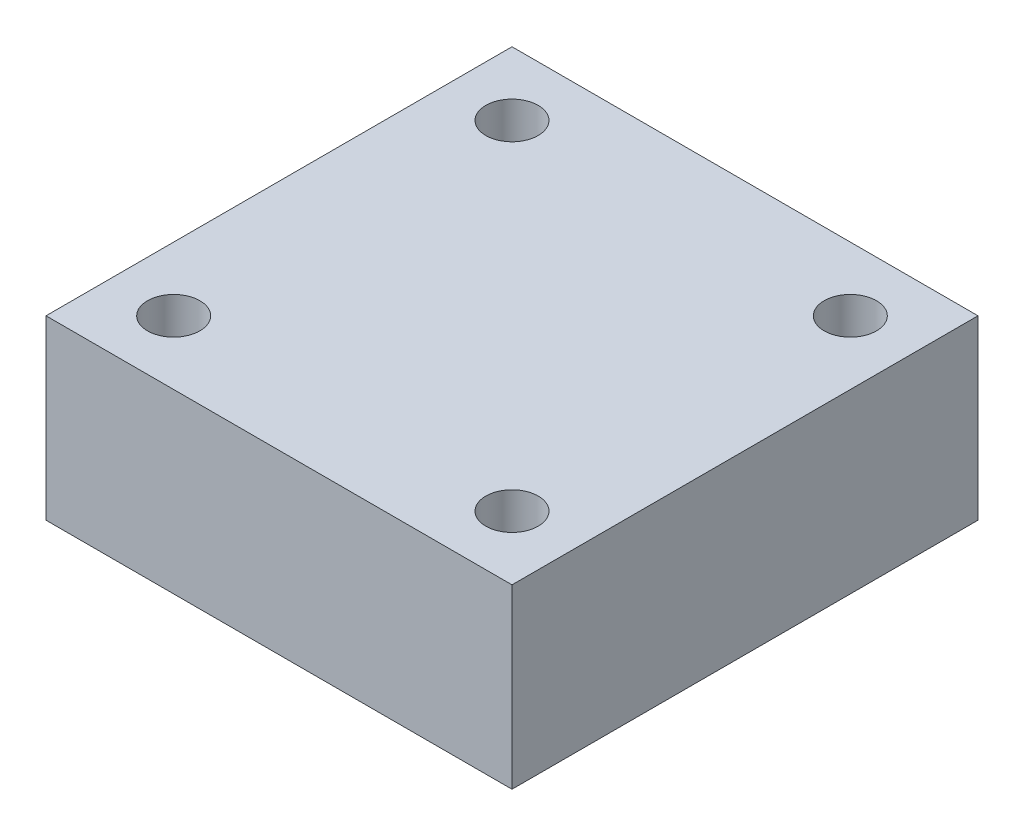
from build123d import *

# Parameters (mm, degrees)
SKETCH1_W           = 73
SKETCH1_H           = 73
SKETCH1_R           = 4.1
BOSS_EXTRUDE1_DEPTH = 27.734


with BuildPart() as part:
    # Sketch1 → Boss-Extrude1 (new body)
    with BuildSketch(Plane(origin=(0, 0, 0), x_dir=(1, 0, 0), z_dir=(0, 1, 0))):
        Rectangle(SKETCH1_W, SKETCH1_H)
        with Locations((-26.5, 26.5)):
            Circle(SKETCH1_R, mode=Mode.SUBTRACT)
        with Locations((26.5, 26.5)):
            Circle(SKETCH1_R, mode=Mode.SUBTRACT)
        with Locations((26.5, -26.5)):
            Circle(SKETCH1_R, mode=Mode.SUBTRACT)
        with Locations((-26.5, -26.5)):
            Circle(SKETCH1_R, mode=Mode.SUBTRACT)
    extrude(amount=BOSS_EXTRUDE1_DEPTH)


solid = part.part
